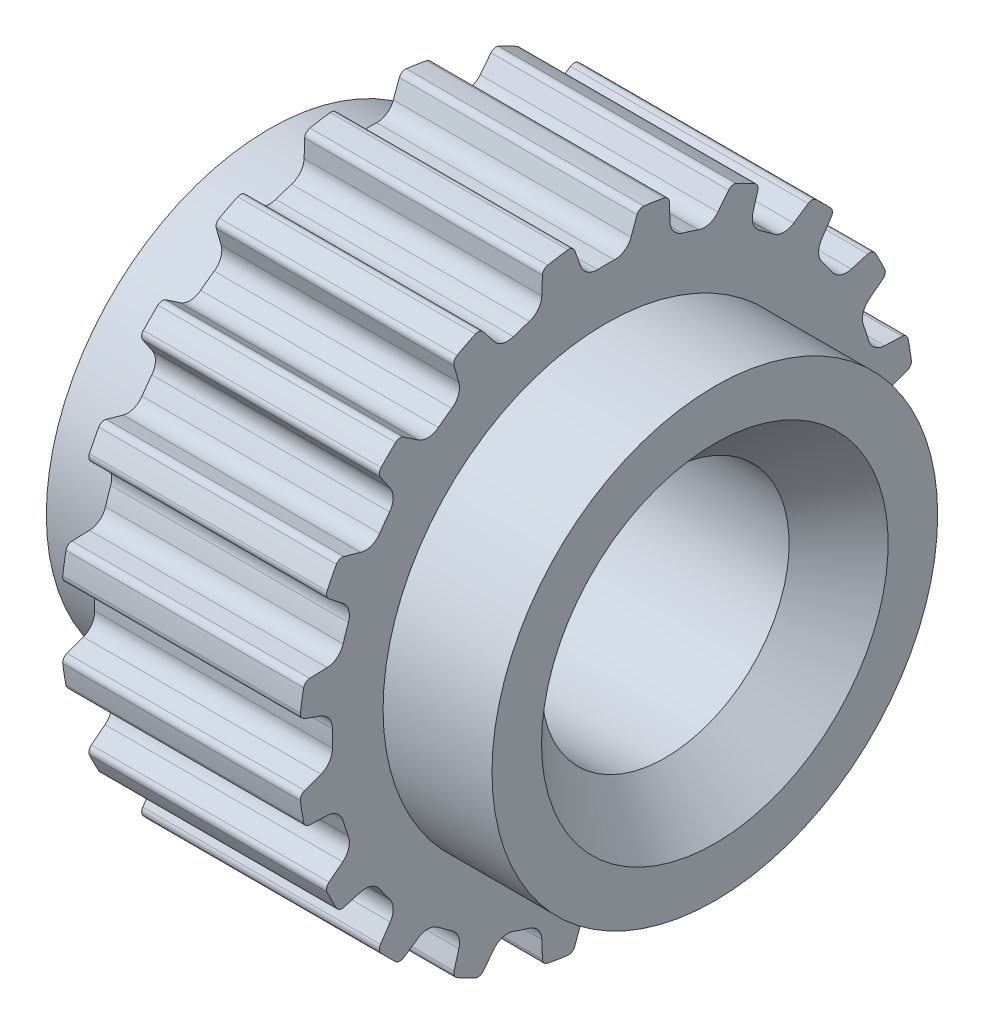
from build123d import *

# Parameters (mm, degrees)
SKETCH_7_R               = 4.5
SKETCH_7_R_2             = 2.5
EXTRUDE_1_DEPTH          = 2
CHAMFER_1_SIZE           = 1
CUT_EXTRUDE_2_REACH      = 13.237
PATTERN_CIRCULAR_3_COUNT = 20


with BuildPart() as part:
    # 草图1 → 旋转1 (revolve)
    with BuildSketch(Plane.XY, mode=Mode.PRIVATE) as revolve_1_sk:
        Polygon((0, 2.5), (0, 6.216), (4.8, 6.216), (4.8, 4.5), (7, 4.5), (7, 2.5), align=None)
    revolve(revolve_1_sk.sketch.rotate(Axis((0, 0, 0), (1, 0, 0)), 90), axis=Axis((0, 0, 0), (1, 0, 0)))

    # 草图7 → 凸台-拉伸1 (add)
    with BuildSketch(Plane.ZY):
        Circle(SKETCH_7_R)
        Circle(SKETCH_7_R_2, mode=Mode.SUBTRACT)
    extrude(amount=EXTRUDE_1_DEPTH)

    # 倒角1
    chamfer_1_edges = [part.edges().sort_by_distance(p)[0] for p in [
        (-2, 0, -2.5),
        (7, 0, -2.5),
    ]]
    chamfer(chamfer_1_edges, length=CHAMFER_1_SIZE)

    # 草图6 → 切除-拉伸2 (cut, up to next)
    with BuildSketch(Plane(origin=(0, 0, 0), x_dir=(0, 0, -1), z_dir=(1, 0, 0)), mode=Mode.PRIVATE) as cut_extrude_2_sk1:
        with BuildLine():
            Line((0.628892154, 6.083942447), (0.508636647, 5.753543158))
            ThreePointArc((0.508636647, 5.753543158), (0.37608692, 5.583509724), (0.169037886, 5.523413998))
            ThreePointArc((0.169037886, 5.523413998), (0, 5.526), (-0.169037886, 5.523413998))
            ThreePointArc((-0.169037886, 5.523413998), (-0.37608692, 5.583509724), (-0.508636647, 5.753543158))
            Line((-0.508636647, 5.753543158), (-0.628892154, 6.083942447))
            ThreePointArc((-0.628892154, 6.083942447), (-0.683213244, 6.150375621), (-0.767095045, 6.168486135))
            ThreePointArc((-0.767095045, 6.168486135), (-0.831556257, 6.160127449), (-0.895926539, 6.151095157))
            Line((-0.895926539, 6.151095157), (-1.394022413, 7.519602325))
            ThreePointArc((-1.394022413, 7.519602325), (0, 7.647726303), (1.394022413, 7.519602325))
            Line((1.394022413, 7.519602325), (0.895926539, 6.151095157))
            ThreePointArc((0.895926539, 6.151095157), (0.831556257, 6.160127449), (0.767095045, 6.168486135))
            ThreePointArc((0.767095045, 6.168486135), (0.683213244, 6.150375621), (0.628892154, 6.083942447))
        make_face()
    cut_extrude_2_tool1 = extrude(cut_extrude_2_sk1.sketch, amount=CUT_EXTRUDE_2_REACH, mode=Mode.PRIVATE) & part.part
    cut_extrude_2 = cut_extrude_2_tool1.solids().sort_by_distance((0, 6.761029, 0))[0]
    add(cut_extrude_2, mode=Mode.SUBTRACT)

    # 阵列(圆周)3: 切除-拉伸2 ×20 about axis
    pattern_circular_3_axis = Axis((0, 0, 0), (1, 0, 0))
    for i in range(1, PATTERN_CIRCULAR_3_COUNT):
        add(cut_extrude_2.rotate(pattern_circular_3_axis, i * 360 / PATTERN_CIRCULAR_3_COUNT), mode=Mode.SUBTRACT)


solid = part.part
